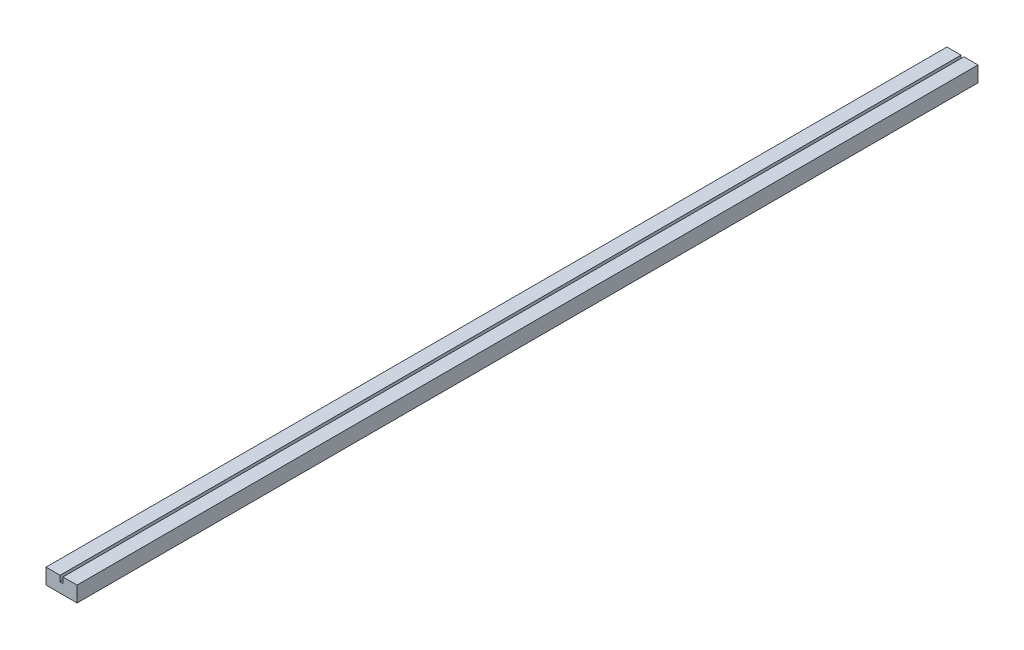
from build123d import *

# Parameters (mm, degrees)
SKETCH1_W           = 101.6
SKETCH1_H           = 50.8
BOSS_EXTRUDE1_DEPTH = 2946.4
CUT_EXTRUDE1_DEPTH  = 19.05


with BuildPart() as part:
    # Sketch1 → Boss-Extrude1 (new body)
    with BuildSketch(Plane.XY):
        with Locations((50.8, 25.4)):
            Rectangle(SKETCH1_W, SKETCH1_H)
    extrude(amount=BOSS_EXTRUDE1_DEPTH)

    # Sketch2 → Cut-Extrude1 (cut)
    with BuildSketch(Plane(origin=(0, 50.8, 0), x_dir=(1, 0, 0), z_dir=(0, 1, 0))):
        Polygon((50.8, -2946.4), (46.0375, -2946.4), (46.0375, 0), (55.5625, 0), (55.5625, -2946.4), align=None)
    extrude(amount=-CUT_EXTRUDE1_DEPTH, mode=Mode.SUBTRACT)


solid = part.part
